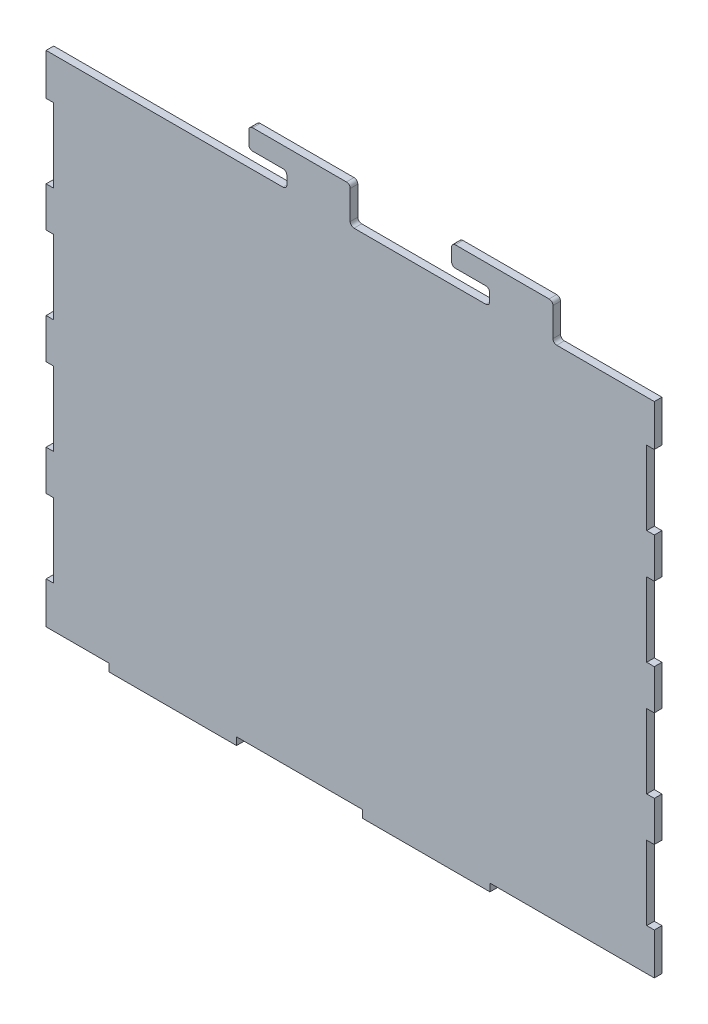
from build123d import *

# Parameters (mm, degrees)
CROQUIS1_W              = 240
CROQUIS1_H              = 200
SALIENTE_EXTRUIR1_DEPTH = 3
CROQUIS2_W              = 3
CROQUIS2_H              = 29.2
CROQUIS2_W_2            = 24.85
CROQUIS2_H_2            = 3
CROQUIS2_W_3            = 49.7
CROQUIS2_W_4            = 66.784595416
CORTAR_EXTRUIR1_DEPTH   = 4
SALIENTE_EXTRUIR2_DEPTH = 3
REDONDEO1_R             = 1.5


with BuildPart() as part:
    # Croquis1 → Saliente-Extruir1 (new body)
    with BuildSketch(Plane.XY):
        Rectangle(CROQUIS1_W, CROQUIS1_H)
    extrude(amount=SALIENTE_EXTRUIR1_DEPTH)

    # Croquis2 → Cortar-Extruir1 (cut, through all)
    with BuildSketch(Plane(origin=(0, 0, 0), x_dir=(-1, 0, 0), z_dir=(0, 0, -1))):
        with Locations((-118.5, -66)):
            Rectangle(CROQUIS2_W, CROQUIS2_H)
        with Locations((-118.5, -21)):
            Rectangle(CROQUIS2_W, CROQUIS2_H)
        with Locations((-118.5, 24)):
            Rectangle(CROQUIS2_W, CROQUIS2_H)
        with Locations((-118.5, 69)):
            Rectangle(CROQUIS2_W, CROQUIS2_H)
        with Locations((107.575, -98.5)):
            Rectangle(CROQUIS2_W_2, CROQUIS2_H_2)
        with Locations((20, -98.5)):
            Rectangle(CROQUIS2_W_3, CROQUIS2_H_2)
        with Locations((-88.542297708, -98.5)):
            Rectangle(CROQUIS2_W_4, CROQUIS2_H_2)
        with Locations((118.5, -66)):
            Rectangle(CROQUIS2_W, CROQUIS2_H)
        with Locations((118.5, -21)):
            Rectangle(CROQUIS2_W, CROQUIS2_H)
        with Locations((118.5, 24)):
            Rectangle(CROQUIS2_W, CROQUIS2_H)
        with Locations((118.5, 69)):
            Rectangle(CROQUIS2_W, CROQUIS2_H)
    extrude(amount=-CORTAR_EXTRUIR1_DEPTH, mode=Mode.SUBTRACT)

    # Croquis3 → Saliente-Extruir2 (add)
    with BuildSketch(Plane(origin=(0, 0, 0), x_dir=(-1, 0, 0), z_dir=(0, 0, -1))):
        with BuildLine():
            Line((-55, 100), (-55, 104.8))
            ThreePointArc((-55, 104.8), (-54.560660172, 105.860660172), (-53.5, 106.3))
            Line((-53.5, 106.3), (-41.5, 106.3))
            ThreePointArc((-41.5, 106.3), (-40.439339828, 106.739339828), (-40, 107.8))
            Line((-40, 107.8), (-40, 112.8))
            ThreePointArc((-40, 112.8), (-40.439339828, 113.860660172), (-41.5, 114.3))
            Line((-41.5, 114.3), (-78.5, 114.3))
            ThreePointArc((-78.5, 114.3), (-79.560660172, 113.860660172), (-80, 112.8))
            Line((-80, 112.8), (-80, 100))
            Line((-80, 100), (-55, 100))
        make_face()
        with BuildLine():
            Line((0, 100), (25, 100))
            Line((25, 100), (25, 104.8))
            ThreePointArc((25, 104.8), (25.439339828, 105.860660172), (26.5, 106.3))
            Line((26.5, 106.3), (38.5, 106.3))
            ThreePointArc((38.5, 106.3), (39.560660172, 106.739339828), (40, 107.8))
            Line((40, 107.8), (40, 112.8))
            ThreePointArc((40, 112.8), (39.560660172, 113.860660172), (38.5, 114.3))
            Line((38.5, 114.3), (1.5, 114.3))
            ThreePointArc((1.5, 114.3), (0.439339828, 113.860660172), (0, 112.8))
            Line((0, 112.8), (0, 100))
        make_face()
    extrude(amount=-SALIENTE_EXTRUIR2_DEPTH)

    # Redondeo1
    redondeo1_edges = [part.edges().sort_by_distance(p)[0] for p in [
        (55, 100, 1.5),
        (80, 100, 1.5),
        (-25, 100, 1.5),
        (0, 100, 1.5),
    ]]
    fillet(redondeo1_edges, radius=REDONDEO1_R)


solid = part.part
